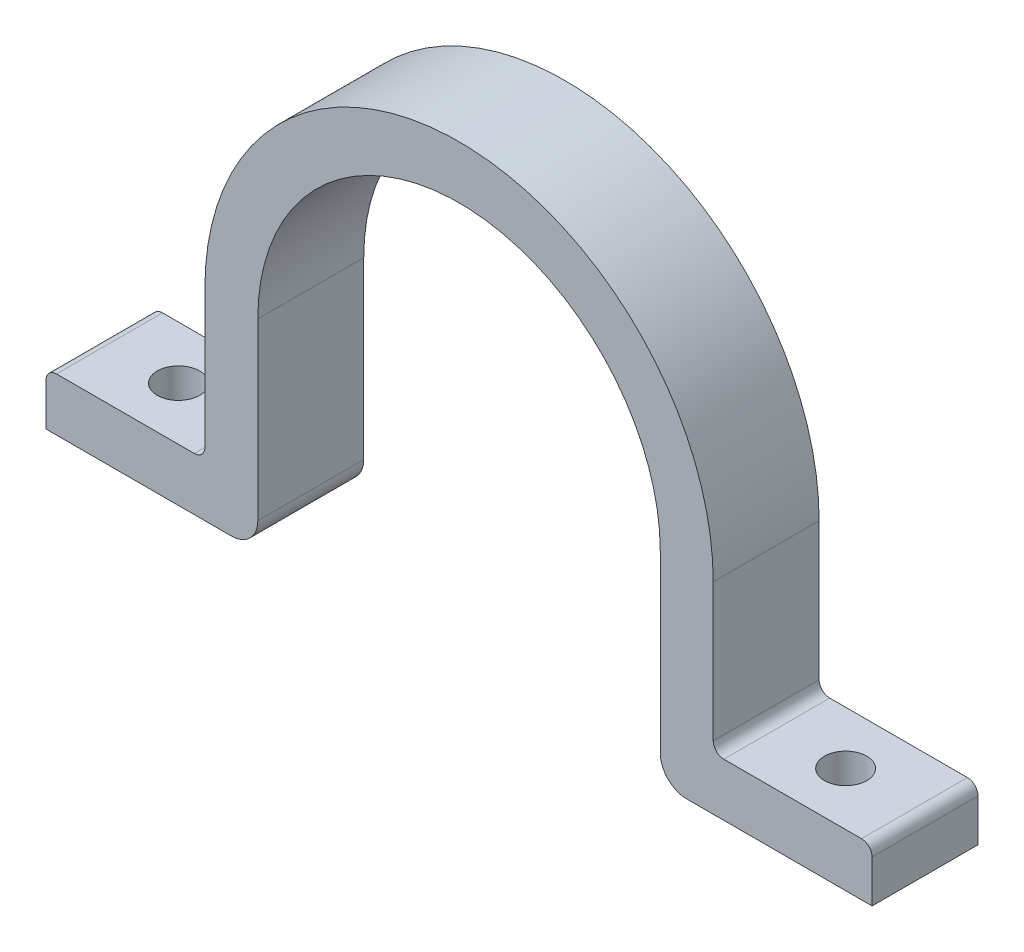
from build123d import *

# Parameters (mm, degrees)
BOSS_EXTRUDE1_DEPTH = 20
SKETCH3_R           = 4
CUT_EXTRUDE2_DEPTH  = 20
FILLET3_R           = 2
FILLET4_R           = 5


with BuildPart() as part:
    # Sketch1 → Boss-Extrude1 (new body)
    with BuildSketch(Plane.XY):
        with BuildLine():
            Line((-38, -38), (-78, -38))
            Line((-78, -38), (-78, -28))
            Line((-78, -28), (-48, -28))
            Line((-48, -28), (-48, 0))
            ThreePointArc((-48, 0), (0, 48), (48, 0))
            Line((48, 0), (48, -28))
            Line((48, -28), (78, -28))
            Line((78, -28), (78, -38))
            Line((78, -38), (38, -38))
            Line((38, -38), (38, 0))
            ThreePointArc((38, 0), (0, 38), (-38, 0))
            Line((-38, 0), (-38, -38))
        make_face()
    extrude(amount=BOSS_EXTRUDE1_DEPTH)

    # Sketch3 → Cut-Extrude2 (cut)
    with BuildSketch(Plane(origin=(0, -28, 0), x_dir=(1, 0, 0), z_dir=(0, 1, 0))):
        with Locations((-63, -10)):
            Circle(SKETCH3_R)
        with Locations((63, -10)):
            Circle(SKETCH3_R)
    extrude(amount=-CUT_EXTRUDE2_DEPTH, mode=Mode.SUBTRACT)

    # Fillet3
    fillet3_edges = [part.edges().sort_by_distance(p)[0] for p in [
        (48, -28, 10),
        (78, -28, 10),
        (-78, -28, 10),
        (-48, -28, 10),
    ]]
    fillet(fillet3_edges, radius=FILLET3_R)

    # Fillet4
    fillet4_edges = [part.edges().sort_by_distance(p)[0] for p in [
        (38, -38, 10),
        (-38, -38, 10),
    ]]
    fillet(fillet4_edges, radius=FILLET4_R)


solid = part.part
